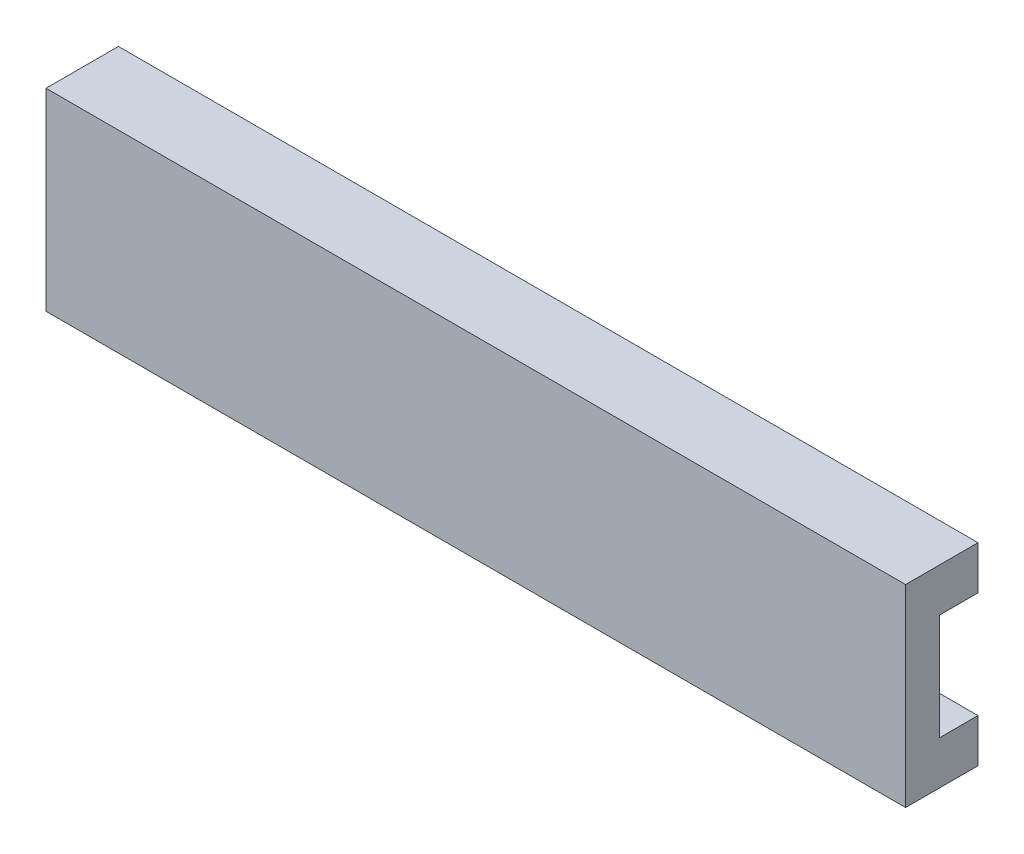
from build123d import *

# Parameters (mm, degrees)
BOSS_EXTRUDE1_DEPTH = 178


with BuildPart() as part:
    # Sketch1 → Boss-Extrude1 (new body)
    with BuildSketch(Plane(origin=(0, 0, 0), x_dir=(0, 0, -1), z_dir=(1, 0, 0))):
        Polygon((0, 0), (0, 40), (15, 40), (15, 31), (7, 31), (7, 9), (15, 9), (15, 0), align=None)
    extrude(amount=-BOSS_EXTRUDE1_DEPTH)


solid = part.part
